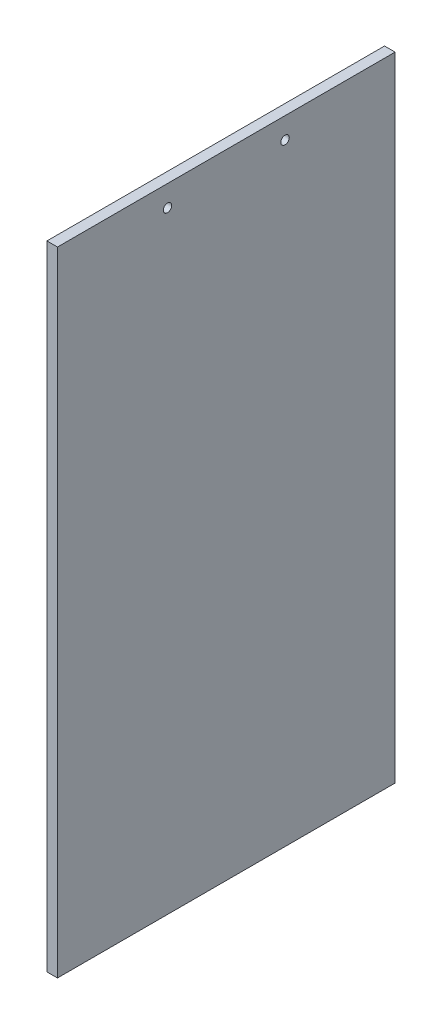
from build123d import *

# Parameters (mm, degrees)
SKETCH_1_W          = 180
SKETCH_1_H          = 300
EXTRUDE_1_DEPTH     = 5
CUT_EXTRUDE_1_REACH = 7
SKETCH_2_R          = 2
SKETCH_4_W          = 10
SKETCH_4_H          = 300
CUT_EXTRUDE_3_DEPTH = 10


with BuildPart() as part:
    # 草图1 → 凸台-拉伸1 (new body)
    with BuildSketch(Plane(origin=(0, 0, 0), x_dir=(0, 0, -1), z_dir=(1, 0, 0))):
        with Locations((90, -150)):
            Rectangle(SKETCH_1_W, SKETCH_1_H)
    extrude(amount=EXTRUDE_1_DEPTH)

    # 草图2 → 切除-拉伸1 (cut, up to next)
    with BuildSketch(Plane(origin=(5, 0, 0), x_dir=(0, 0, -1), z_dir=(1, 0, 0)), mode=Mode.PRIVATE) as cut_extrude_1_sk1:
        with Locations((62.15, -10)):
            Circle(SKETCH_2_R)
    cut_extrude_1_tool1 = extrude(cut_extrude_1_sk1.sketch, amount=-CUT_EXTRUDE_1_REACH, mode=Mode.PRIVATE) & part.part
    add(cut_extrude_1_tool1.solids().sort_by_distance((5, -10, -62.15))[0], mode=Mode.SUBTRACT)
    # 草图2 → 切除-拉伸1 (cut, up to next)
    with BuildSketch(Plane(origin=(5, 0, 0), x_dir=(0, 0, -1), z_dir=(1, 0, 0)), mode=Mode.PRIVATE) as cut_extrude_1_sk2:
        with Locations((117.85, -10)):
            Circle(SKETCH_2_R)
    cut_extrude_1_tool2 = extrude(cut_extrude_1_sk2.sketch, amount=-CUT_EXTRUDE_1_REACH, mode=Mode.PRIVATE) & part.part
    add(cut_extrude_1_tool2.solids().sort_by_distance((5, -10, -117.85))[0], mode=Mode.SUBTRACT)

    # 草图4 → 切除-拉伸3 (cut)
    with BuildSketch(Plane(origin=(5, 0, 0), x_dir=(0, 0, -1), z_dir=(1, 0, 0))):
        with Locations((5, -150)):
            Rectangle(SKETCH_4_W, SKETCH_4_H)
        with Locations((175, -150)):
            Rectangle(SKETCH_4_W, SKETCH_4_H)
    extrude(amount=-CUT_EXTRUDE_3_DEPTH, mode=Mode.SUBTRACT)


solid = part.part
